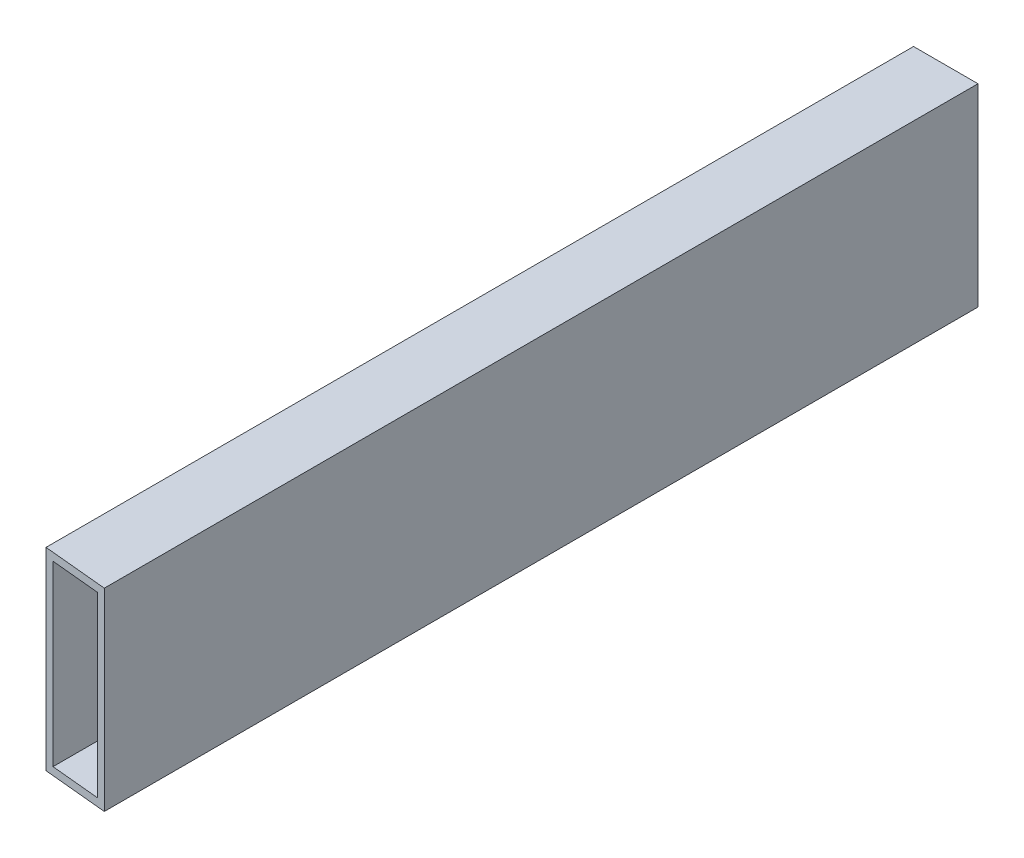
from build123d import *

# Parameters (mm, degrees)
SKETCH2_W               = 9.652
SKETCH2_H               = 3.048
SKETCH2_W_2             = 3.048
SKETCH2_H_2             = 35.052
BOSS_EXTRUDE1_DEPTH     = 343
SKETCH3_W               = 25.4
SKETCH3_H               = 76.2
SKETCH3_W_2             = 19.304
SKETCH3_H_2             = 70.104
BOSS_EXTRUDE2_DEPTH     = 50
CUT_EXTRUDE1_DEPTH      = 1
CUT_EXTRUDE1_DEPTH_BACK = 77.2


with BuildPart() as part:
    # Sketch2 → Boss-Extrude1 (new body)
    with BuildSketch(Plane.XY):
        Polygon((-12.7, 0), (-9.652, 0), (-9.652, 35.052), (-9.652, 38.1), (-12.7, 38.1), align=None)
        with Locations((-4.826, 36.576)):
            Rectangle(SKETCH2_W, SKETCH2_H)
        Polygon((0, 38.1), (0, 35.052), (9.652, 35.052), (9.652, 0), (12.7, 0), (12.7, 38.1), align=None)
        with Locations((11.176, -17.526)):
            Rectangle(SKETCH2_W_2, SKETCH2_H_2)
        Polygon((-9.652, -35.052), (-9.652, 0), (-12.7, 0), (-12.7, -38.1), (0, -38.1), (0, -35.052), align=None)
        Polygon((9.652, -35.052), (0, -35.052), (0, -38.1), (12.7, -38.1), (12.7, -35.052), align=None)
    extrude(amount=BOSS_EXTRUDE1_DEPTH)

    # Sketch3 → Boss-Extrude2 (add)
    with BuildSketch(Plane.XY.offset(343)):
        Rectangle(SKETCH3_W, SKETCH3_H)
        Rectangle(SKETCH3_W_2, SKETCH3_H_2, mode=Mode.SUBTRACT)
    extrude(amount=BOSS_EXTRUDE2_DEPTH)

    # Sketch4 → Cut-Extrude1 (cut, two sides)
    with BuildSketch(Plane(origin=(0, 38.1, 0), x_dir=(1, 0, 0), z_dir=(0, 1, 0))) as cut_extrude1_sk:
        Polygon((89.351881, -403.747167587), (94.309709366, -352.043247646), (12.7, -383.524571297), (12.7, -393), (-12.7, -393), (-12.7, -341.782211865), (-94.309709366, -333.956752354), (-99.267537732, -385.660672296), align=None)
        Polygon((12.7, -383.524571297), (94.309709366, -352.043247646), (12.7, -344.217788135), align=None)
        Polygon((12.7, -383.524571297), (12.7, -344.217788135), (0, -343), (-9.501519639, -392.088910403), align=None)
        Polygon((12.7, -393), (12.7, -383.524571297), (-9.501519639, -392.088910403), (0, -343), (-12.7, -341.782211865), (-12.7, -393), align=None)
    extrude(amount=CUT_EXTRUDE1_DEPTH, mode=Mode.SUBTRACT)
    extrude(cut_extrude1_sk.sketch, amount=-CUT_EXTRUDE1_DEPTH_BACK, mode=Mode.SUBTRACT)


solid = part.part
